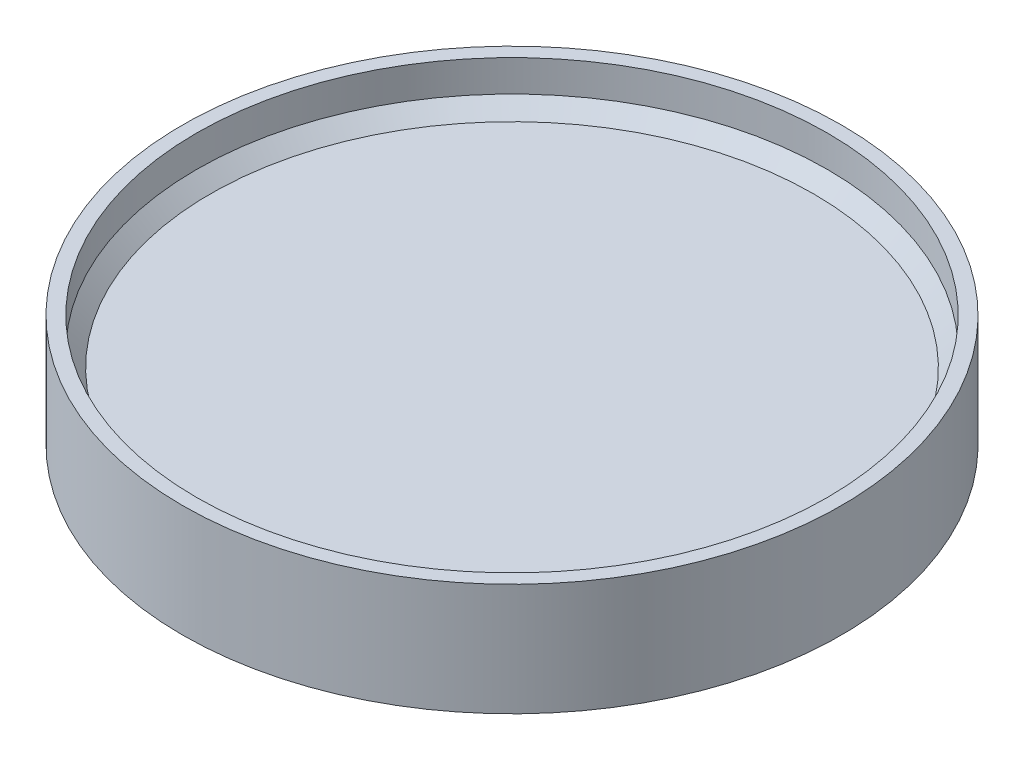
from build123d import *

# Parameters (mm, degrees)
CHAMFER1_SIZE = 6.35


with BuildPart() as part:
    # Sketch5 → Revolve1 (revolve)
    with BuildSketch(Plane.XY):
        Polygon((0, 9.525), (142.875, 9.525), (142.875, 30.1625), (149.225, 30.1625), (149.225, -20.6375), (142.875, -20.6375), (142.875, 0), (0, 0), align=None)
    revolve(axis=Axis((0, 0, 0), (0, 1, 0)))

    # Chamfer1
    chamfer1_edges = [part.edges().sort_by_distance(p)[0] for p in [
        (-142.875, 0, 0),
        (-142.875, 9.525, 0),
    ]]
    chamfer(chamfer1_edges, length=CHAMFER1_SIZE)


solid = part.part
